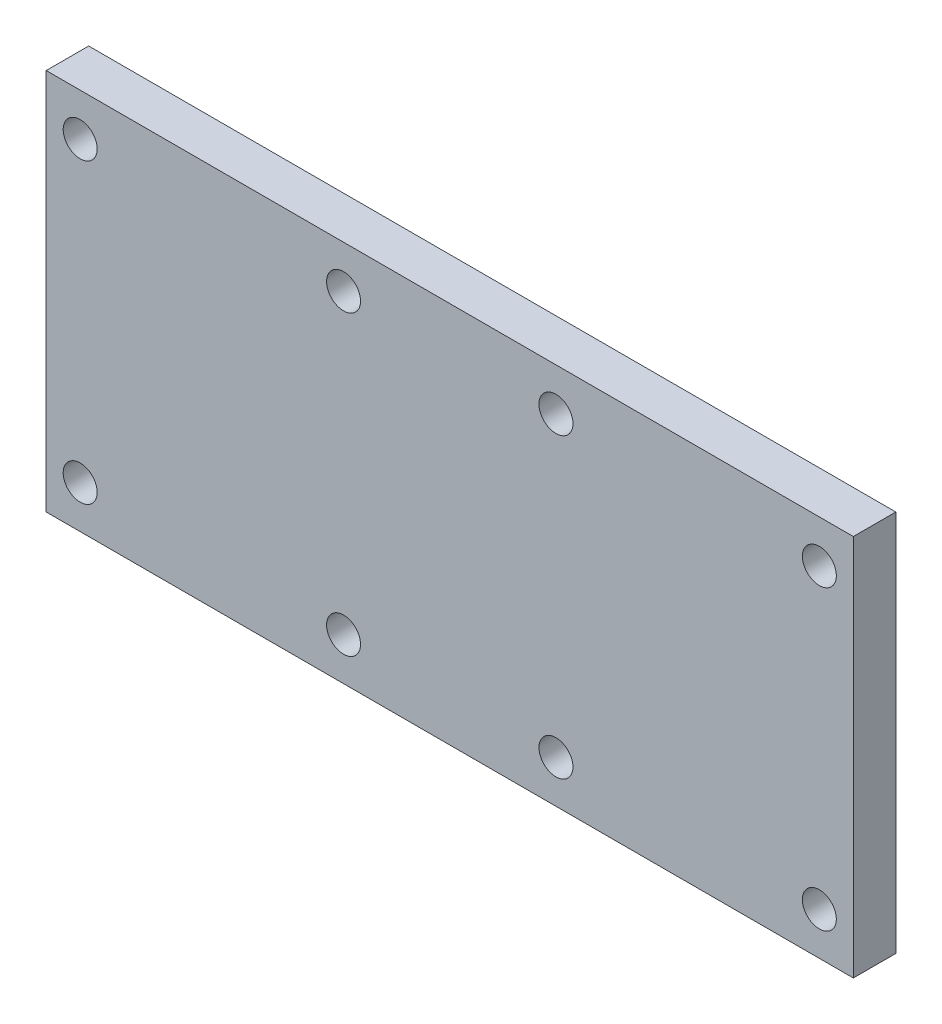
from build123d import *

# Parameters (mm, degrees)
SKETCH1_W           = 95
SKETCH1_H           = 45
BOSS_EXTRUDE1_DEPTH = 5
SKETCH2_R           = 2
CUT_EXTRUDE1_DEPTH  = 6


with BuildPart() as part:
    # Sketch1 → Boss-Extrude1 (new body)
    with BuildSketch(Plane.XY):
        Rectangle(SKETCH1_W, SKETCH1_H)
    extrude(amount=BOSS_EXTRUDE1_DEPTH)

    # Sketch2 → Cut-Extrude1 (cut, through all)
    with BuildSketch(Plane.XY.offset(5)):
        with Locations((43.5, 17.5)):
            Circle(SKETCH2_R)
        with Locations((43.5, -17.5)):
            Circle(SKETCH2_R)
        with Locations((12.5, -17.5)):
            Circle(SKETCH2_R)
        with Locations((12.5, 17.5)):
            Circle(SKETCH2_R)
        with Locations((-12.5, 17.5)):
            Circle(SKETCH2_R)
        with Locations((-12.5, -17.5)):
            Circle(SKETCH2_R)
        with Locations((-43.5, -17.5)):
            Circle(SKETCH2_R)
        with Locations((-43.5, 17.5)):
            Circle(SKETCH2_R)
    extrude(amount=-CUT_EXTRUDE1_DEPTH, mode=Mode.SUBTRACT)


solid = part.part
